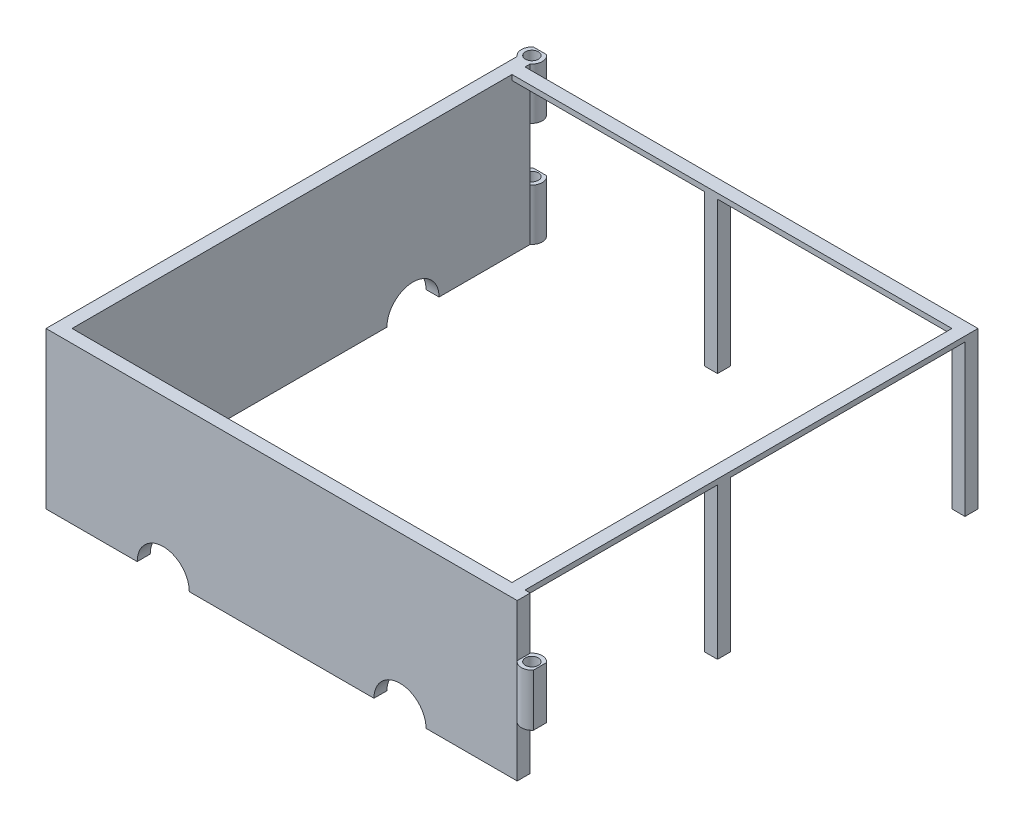
from build123d import *

# Parameters (mm, degrees)
BOSS_EXTRUDE1_DEPTH     = 60
SKETCH2_R               = 2.5
CUT_EXTRUDE1_DEPTH      = 60
SKETCH4_W               = 7.122498999
SKETCH4_H               = 20
CUT_EXTRUDE3_DEPTH      = 2.5
CUT_EXTRUDE3_DEPTH_BACK = 189
CUT_EXTRUDE4_DEPTH      = 21
CUT_EXTRUDE4_DEPTH_BACK = 41
SKETCH6_W               = 8.505604829
SKETCH6_H               = 20.5
CUT_EXTRUDE6_DEPTH      = 2.5
CUT_EXTRUDE6_DEPTH_BACK = 188.122498999
CUT_EXTRUDE7_DEPTH      = 1
CUT_EXTRUDE7_DEPTH_BACK = 61
BOSS_EXTRUDE2_DEPTH     = 2
SKETCH9_W               = 5
SKETCH9_H               = 5
BOSS_EXTRUDE3_DEPTH     = 58


with BuildPart() as part:
    # Sketch1 → Boss-Extrude1 (new body)
    with BuildSketch(Plane(origin=(0, 0, 0), x_dir=(1, 0, 0), z_dir=(0, 1, 0))):
        with BuildLine():
            Line((0, 0), (180, 0))
            Line((180, 0), (180.877501001, 0))
            ThreePointArc((180.877501001, 0), (188, 2.5), (180.877501001, 5))
            Line((180.877501001, 5), (180, 5))
            Line((180, 5), (5, 5))
            Line((5, 5), (5, 180))
            Line((5, 180), (5, 180.877501001))
            ThreePointArc((5, 180.877501001), (2.5, 188), (0, 180.877501001))
            Line((0, 180.877501001), (0, 180))
            Line((0, 180), (0, 0))
        make_face()
    extrude(amount=BOSS_EXTRUDE1_DEPTH)

    # Sketch2 → Cut-Extrude1 (cut)
    with BuildSketch(Plane(origin=(0, 60, 0), x_dir=(1, 0, 0), z_dir=(0, 1, 0))):
        with Locations((184, 2.5)):
            Circle(SKETCH2_R)
        with Locations((2.5, 184)):
            Circle(SKETCH2_R)
    extrude(amount=-CUT_EXTRUDE1_DEPTH, mode=Mode.SUBTRACT)

    # Sketch4 → Cut-Extrude3 (cut, two sides)
    with BuildSketch(Plane.XY) as cut_extrude3_sk:
        with BuildLine():
            ThreePointArc((35, 0), (45, -10), (55, 0))
            Line((55, 0), (45, 0))
            Line((45, 0), (35, 0))
        make_face()
        with BuildLine():
            Line((45, 0), (55, 0))
            ThreePointArc((55, 0), (45, 10), (35, 0))
            Line((35, 0), (45, 0))
        make_face()
        with BuildLine():
            ThreePointArc((125.877501001, 0), (135.877501001, -10), (145.877501001, 0))
            Line((145.877501001, 0), (135.877501001, 0))
            Line((135.877501001, 0), (125.877501001, 0))
        make_face()
        with BuildLine():
            Line((135.877501001, 0), (145.877501001, 0))
            ThreePointArc((145.877501001, 0), (135.877501001, 10), (125.877501001, 0))
            Line((125.877501001, 0), (135.877501001, 0))
        make_face()
        with Locations((184.438750501, 10)):
            Rectangle(SKETCH4_W, SKETCH4_H)
        with Locations((184.438750501, 50)):
            Rectangle(SKETCH4_W, SKETCH4_H)
    extrude(amount=CUT_EXTRUDE3_DEPTH, mode=Mode.SUBTRACT)
    extrude(cut_extrude3_sk.sketch, amount=-CUT_EXTRUDE3_DEPTH_BACK, mode=Mode.SUBTRACT)

    # Sketch5 → Cut-Extrude4 (cut, two sides)
    with BuildSketch(Plane(origin=(0, 40, 0), x_dir=(1, 0, 0), z_dir=(0, 1, 0))) as cut_extrude4_sk:
        with BuildLine():
            Line((187.122498999, 5), (187.122498999, 2.5))
            Line((187.122498999, 2.5), (187.122498999, 0))
            ThreePointArc((187.122498999, 0), (188, 2.5), (187.122498999, 5))
        make_face()
    extrude(amount=CUT_EXTRUDE4_DEPTH, mode=Mode.SUBTRACT)
    extrude(cut_extrude4_sk.sketch, amount=-CUT_EXTRUDE4_DEPTH_BACK, mode=Mode.SUBTRACT)

    # Sketch6 → Cut-Extrude6 (cut, two sides)
    with BuildSketch(Plane.ZY) as cut_extrude6_sk:
        with BuildLine():
            ThreePointArc((-145.877501001, 0), (-135.877501001, -10), (-125.877501001, 0))
            Line((-125.877501001, 0), (-135.877501001, 0))
            Line((-135.877501001, 0), (-145.877501001, 0))
        make_face()
        with BuildLine():
            Line((-135.877501001, 0), (-125.877501001, 0))
            ThreePointArc((-125.877501001, 0), (-135.877501001, 10), (-145.877501001, 0))
            Line((-145.877501001, 0), (-135.877501001, 0))
        make_face()
        with BuildLine():
            ThreePointArc((-55, 0), (-45, -10), (-35, 0))
            Line((-35, 0), (-45, 0))
            Line((-45, 0), (-55, 0))
        make_face()
        with BuildLine():
            Line((-45, 0), (-35, 0))
            ThreePointArc((-35, 0), (-45, 10), (-55, 0))
            Line((-55, 0), (-45, 0))
        make_face()
        with Locations((-185.130303416, 30)):
            Rectangle(SKETCH6_W, SKETCH6_H)
    extrude(amount=CUT_EXTRUDE6_DEPTH, mode=Mode.SUBTRACT)
    extrude(cut_extrude6_sk.sketch, amount=-CUT_EXTRUDE6_DEPTH_BACK, mode=Mode.SUBTRACT)

    # Sketch7 → Cut-Extrude7 (cut, two sides)
    with BuildSketch(Plane(origin=(0, 60, 0), x_dir=(1, 0, 0), z_dir=(0, 1, 0))) as cut_extrude7_sk:
        with BuildLine():
            ThreePointArc((5, 187.122498999), (2.5, 188), (0, 187.122498999))
            Line((0, 187.122498999), (2.5, 187.122498999))
            Line((2.5, 187.122498999), (5, 187.122498999))
        make_face()
    extrude(amount=CUT_EXTRUDE7_DEPTH, mode=Mode.SUBTRACT)
    extrude(cut_extrude7_sk.sketch, amount=-CUT_EXTRUDE7_DEPTH_BACK, mode=Mode.SUBTRACT)

    # Sketch8 → Boss-Extrude2 (add)
    with BuildSketch(Plane(origin=(0, 60, 0), x_dir=(1, 0, 0), z_dir=(0, 1, 0))):
        Polygon((178.877501001, 178.877501001), (5, 178.877501001), (5, 173.877501001), (173.877501001, 173.877501001), (173.877501001, 5), (178.877501001, 5), align=None)
    extrude(amount=-BOSS_EXTRUDE2_DEPTH)

    # Sketch9 → Boss-Extrude3 (add)
    with BuildSketch(Plane(origin=(0, 58, 0), x_dir=(-1, 0, 0), z_dir=(0, -1, 0))):
        with Locations((-176.377501001, 176.377501001)):
            Rectangle(SKETCH9_W, SKETCH9_H)
        with Locations((-176.377501001, 81.377501001)):
            Rectangle(SKETCH9_W, SKETCH9_H)
        with Locations((-81.377501001, 176.377501001)):
            Rectangle(SKETCH9_W, SKETCH9_H)
    extrude(amount=BOSS_EXTRUDE3_DEPTH)


solid = part.part
